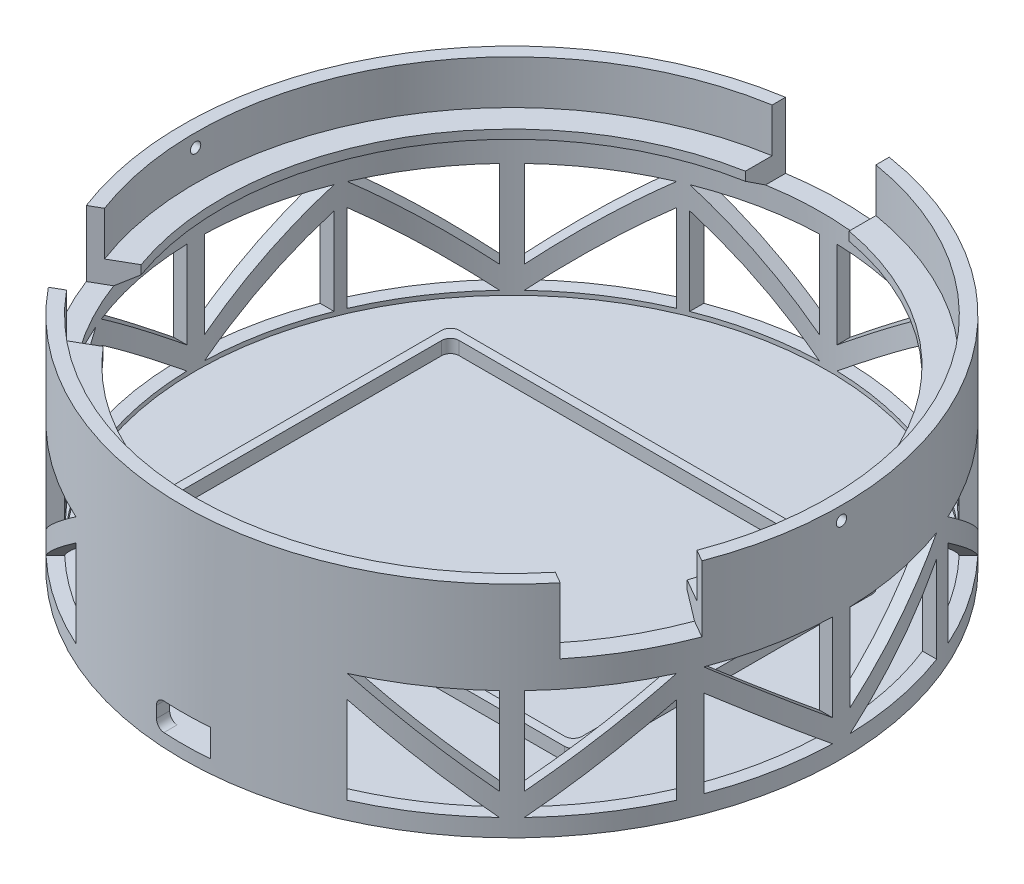
from build123d import *

# Parameters (mm, degrees)
SKETCH1_R               = 95.25
SKETCH1_W               = 118.11
SKETCH1_H               = 88.9
BOSS_EXTRUDE1_DEPTH     = 63.5
SHELL1_T                = -3.81
SKETCH3_W               = 29.972
SKETCH3_H               = 70.630358963
CUT_EXTRUDE1_DEPTH      = 149.920700374
CUT_EXTRUDE1_DEPTH_BACK = 19.05
SKETCH5_R               = 1.5
CUT_EXTRUDE2_DEPTH      = 149.920700374
CUT_EXTRUDE2_DEPTH_BACK = 149.920700374
CUT_EXTRUDE3_DEPTH      = 149.920700548
BOSS_EXTRUDE2_DEPTH     = 3.81
CUT_EXTRUDE4_DEPTH      = 12.7
CIRPATTERN1_COUNT       = 8


with BuildPart() as part:
    # Sketch1 → Boss-Extrude1 (new body)
    with BuildSketch(Plane(origin=(0, 0, 0), x_dir=(1, 0, 0), z_dir=(0, 1, 0))):
        with Locations(Location((0, 0, 0), (0, 0, 270))):
            Circle(SKETCH1_R)
        Rectangle(SKETCH1_W, SKETCH1_H, mode=Mode.SUBTRACT)
        Rectangle(SKETCH1_W, SKETCH1_H)
    extrude(amount=BOSS_EXTRUDE1_DEPTH)

    # Shell1
    shell1_openings = [part.faces().sort_by_distance(p)[0] for p in [
        (0, 63.5, 0),
    ]]
    offset(amount=SHELL1_T, openings=shell1_openings, kind=Kind.INTERSECTION)

    # Sketch2 → Revolve1 (revolve)
    with BuildSketch(Plane.XY, mode=Mode.PRIVATE) as revolve1_sk:
        Polygon((91.44, 50.8), (91.44, 43.18), (83.82, 48.26), (83.82, 50.8), align=None)
    revolve(revolve1_sk.sketch.rotate(Axis((0, 63.5, 0), (0, -1, 0)), 90), axis=Axis((0, 63.5, 0), (0, -1, 0)))

    # Sketch3 → Cut-Extrude1 (cut, two sides)
    with BuildSketch(Plane(origin=(0, 63.5, 0), x_dir=(1, 0, 0), z_dir=(0, 1, 0))) as cut_extrude1_sk:
        with Locations((0, 72.644532699)):
            Rectangle(SKETCH3_W, SKETCH3_H)
        Polygon((39.821168192, -5.686419907), (100.988853333, -41.001599389), (86.002853333, -66.958112791), (24.835168192, -31.642933309), align=None)
        Polygon((-24.835168192, -31.642933309), (-86.002853333, -66.958112791), (-100.988853333, -41.001599389), (-39.821168192, -5.686419907), align=None)
    extrude(amount=CUT_EXTRUDE1_DEPTH, mode=Mode.SUBTRACT)
    extrude(cut_extrude1_sk.sketch, amount=-CUT_EXTRUDE1_DEPTH_BACK, mode=Mode.SUBTRACT)

    # Sketch5 → Cut-Extrude2 (cut, two sides)
    with BuildSketch(Plane(origin=(0, 0, 0), x_dir=(0, 0, -1), z_dir=(1, 0, 0))) as cut_extrude2_sk:
        with Locations((0, 59.69)):
            Circle(SKETCH5_R)
    extrude(amount=CUT_EXTRUDE2_DEPTH, mode=Mode.SUBTRACT)
    extrude(cut_extrude2_sk.sketch, amount=-CUT_EXTRUDE2_DEPTH_BACK, mode=Mode.SUBTRACT)

    # Sketch6 → Cut-Extrude3 (cut, through all)
    with BuildSketch(Plane.XY):
        with BuildLine():
            Line((-5.5, 3.81), (7.8, 3.81))
            Line((7.8, 3.81), (7.8, 11.71))
            Line((7.8, 11.71), (-5.5, 11.71))
            ThreePointArc((-5.5, 11.71), (-7.126345597, 11.036345597), (-7.8, 9.41))
            Line((-7.8, 9.41), (-7.8, 6.11))
            ThreePointArc((-7.8, 6.11), (-7.126345597, 4.483654403), (-5.5, 3.81))
        make_face()
    extrude(amount=CUT_EXTRUDE3_DEPTH, mode=Mode.SUBTRACT)

    # Sketch7 → Boss-Extrude2 (add)
    with BuildSketch(Plane(origin=(0, 3.81, 0), x_dir=(1, 0, 0), z_dir=(0, 1, 0))):
        with BuildLine():
            Line((-59.69, 44.45), (59.69, 44.45))
            ThreePointArc((59.69, 44.45), (61.486051224, 43.706051224), (62.23, 41.91))
            Line((62.23, 41.91), (62.23, -41.91))
            ThreePointArc((62.23, -41.91), (61.486051224, -43.706051224), (59.69, -44.45))
            Line((59.69, -44.45), (-59.69, -44.45))
            ThreePointArc((-59.69, -44.45), (-61.486051224, -43.706051224), (-62.23, -41.91))
            Line((-62.23, -41.91), (-62.23, 41.91))
            ThreePointArc((-62.23, 41.91), (-61.486051224, 43.706051224), (-59.69, 44.45))
        make_face()
        with BuildLine():
            Line((-57.15, -41.91), (57.15, -41.91))
            ThreePointArc((57.15, -41.91), (58.946051224, -41.166051224), (59.69, -39.37))
            Line((59.69, -39.37), (59.69, 39.37))
            ThreePointArc((59.69, 39.37), (58.946051224, 41.166051224), (57.15, 41.91))
            Line((57.15, 41.91), (-57.15, 41.91))
            ThreePointArc((-57.15, 41.91), (-58.946051224, 41.166051224), (-59.69, 39.37))
            Line((-59.69, 39.37), (-59.69, -39.37))
            ThreePointArc((-59.69, -39.37), (-58.946051224, -41.166051224), (-57.15, -41.91))
        make_face(mode=Mode.SUBTRACT)
    extrude(amount=BOSS_EXTRUDE2_DEPTH)

    # Sketch9 → Cut-Extrude4 (cut)
    with BuildSketch(Plane(origin=(95.25, 0, 0), x_dir=(0, 0, -1), z_dir=(1, 0, 0))):
        Polygon((-33.655, 30.29169293), (-33.655, 5.08), (-2.54, 5.08), align=None)
        Polygon((33.655, 30.29169293), (33.655, 5.08), (2.54, 5.08), align=None)
        Polygon((-33.655, 36.83), (-2.54, 11.61830707), (-2.54, 36.83), align=None)
        Polygon((2.54, 11.61830707), (2.54, 36.83), (33.655, 36.83), align=None)
    cut_extrude4 = extrude(amount=-CUT_EXTRUDE4_DEPTH, mode=Mode.SUBTRACT)

    # CirPattern1: Cut-Extrude4 ×8 about axis, 1 skipped
    cirpattern1_axis = Axis((0, 0, 0), (0, -1, 0))
    add([cut_extrude4.rotate(cirpattern1_axis, i * 360 / CIRPATTERN1_COUNT) for i in range(1, CIRPATTERN1_COUNT) if i not in (2,)], mode=Mode.SUBTRACT)


solid = part.part
